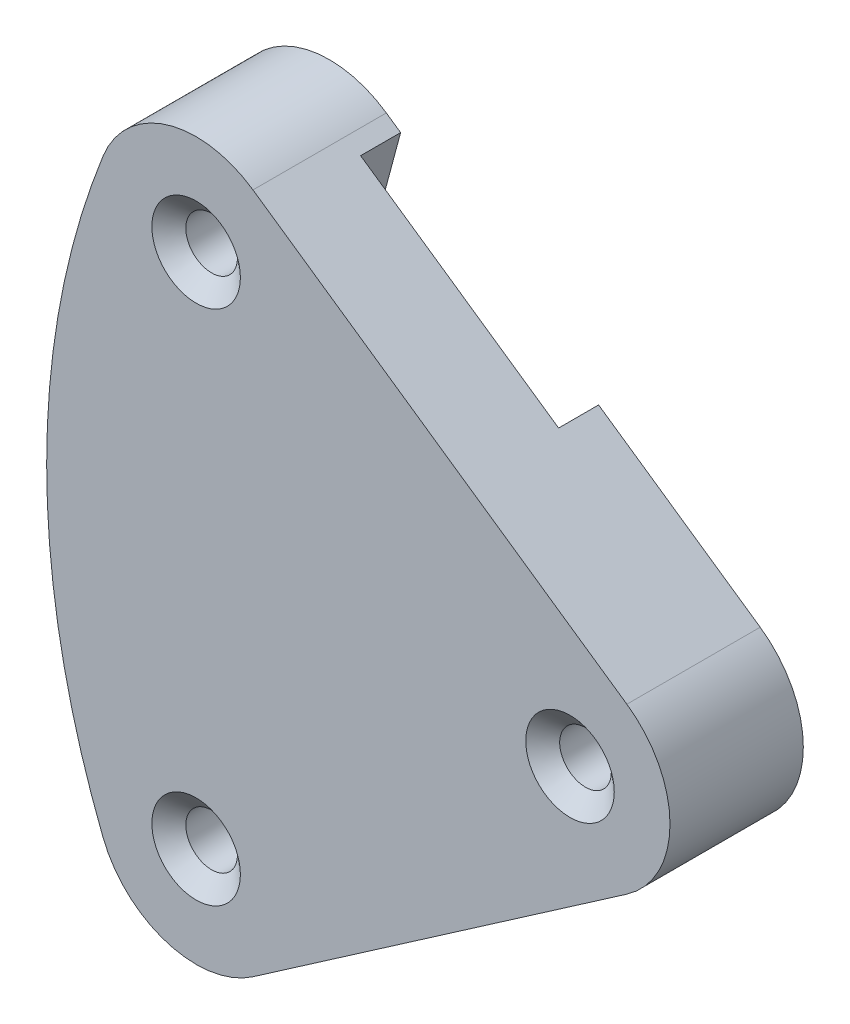
from build123d import *

# Parameters (mm, degrees)
BOSS_EXTRUDE1_DEPTH                               = 12.7
SKETCH2_R                                         = 101.6
SKETCH2_R_2                                       = 76.2
CUT_EXTRUDE1_DEPTH                                = 13.7
FILLET1_R                                         = 9.525
CSK_FOR_8_FLAT_HEAD_MACHINE_SCREW_100_D           = 4.9149
CSK_FOR_8_FLAT_HEAD_MACHINE_SCREW_100_DEPTH       = 12.7
CSK_FOR_8_FLAT_HEAD_MACHINE_SCREW_100_CSINK_D     = 8.4328
CSK_FOR_8_FLAT_HEAD_MACHINE_SCREW_100_CSINK_ANGLE = 100
CUT_EXTRUDE2_DEPTH                                = 6.35
CUT_EXTRUDE3_DEPTH                                = 3.81
SKETCH7_R                                         = 1.397
CUT_EXTRUDE4_DEPTH                                = 3.175
HOLE1_AT_2_COUNT                                  = 2
HOLE1_AT_2_PITCH                                  = 9.3599
HOLE1_AT_3_COUNT                                  = 2
HOLE1_AT_3_PITCH                                  = 38.818175673
HOLE1_AT_4_COUNT                                  = 2
HOLE1_AT_4_PITCH                                  = 40.17317123
F_2_CLEARANCE_HOLE1_D                             = 2.7051
F_2_CLEARANCE_HOLE1_DEPTH                         = 4.7625


with BuildPart() as part:
    # Sketch1 → Boss-Extrude1 (new body)
    with BuildSketch(Plane.XY):
        Polygon((33.299680929, 0), (-33.299680929, 46.0375), (-33.299680929, -46.0375), align=None)
    extrude(amount=BOSS_EXTRUDE1_DEPTH)

    # Sketch2 → Cut-Extrude1 (cut, through all)
    with BuildSketch(Plane.XY.offset(12.7)):
        with Locations((42.900319071, 0)):
            Circle(SKETCH2_R)
        with Locations((42.900319071, 0)):
            Circle(SKETCH2_R_2, mode=Mode.SUBTRACT)
    extrude(amount=-CUT_EXTRUDE1_DEPTH, mode=Mode.SUBTRACT)

    # Fillet1
    fillet1_edges = [part.edges().sort_by_distance(p)[0] for p in [
        (-22.72460624, -38.727369881, 6.35),
        (-22.72460624, 38.727369881, 6.35),
        (33.299680929, 0, 6.35),
    ]]
    fillet(fillet1_edges, radius=FILLET1_R)

    # CSK for #8 Flat Head Machine Screw (100)1
    with Locations(Plane.XY.offset(12.7)):
        with Locations((-19.063658953, -24.617494846), (-19.063658953, 24.617494846), (16.54881886, 0)):
            CounterSinkHole(CSK_FOR_8_FLAT_HEAD_MACHINE_SCREW_100_D / 2, CSK_FOR_8_FLAT_HEAD_MACHINE_SCREW_100_CSINK_D / 2, depth=CSK_FOR_8_FLAT_HEAD_MACHINE_SCREW_100_DEPTH, counter_sink_angle=CSK_FOR_8_FLAT_HEAD_MACHINE_SCREW_100_CSINK_ANGLE)

    # Sketch5 → Cut-Extrude2 (cut)
    with BuildSketch(Plane(origin=(0, 0, 0), x_dir=(-1, 0, 0), z_dir=(0, 0, -1))):
        with BuildLine():
            Line((30.823542048, 19.267389595), (-18.192319797, 6.133628997))
            ThreePointArc((-18.192319797, 6.133628997), (-22.89881886, 0), (-18.192319797, -6.133628997))
            Line((-18.192319797, -6.133628997), (30.823542048, -19.267389595))
            ThreePointArc((30.823542048, -19.267389595), (33.299680929, 0), (30.823542048, 19.267389595))
        make_face()
    extrude(amount=-CUT_EXTRUDE2_DEPTH, mode=Mode.SUBTRACT)

    # Sketch6 → Cut-Extrude3 (cut)
    with BuildSketch(Plane(origin=(0, 0, 0), x_dir=(-1, 0, 0), z_dir=(0, 0, -1))):
        Polygon((16.588726313, -15.453182214), (-4.265612277, -9.86527903), (-8.867414899, -27.039440222), (11.986923691, -32.627343405), align=None)
        Polygon((11.986923691, 32.627343405), (-8.867414899, 27.039440222), (-4.265612277, 9.86527903), (16.588726313, 15.453182214), align=None)
    extrude(amount=-CUT_EXTRUDE3_DEPTH, mode=Mode.SUBTRACT)

    # Sketch7 → Cut-Extrude4 (cut)
    with BuildSketch(Plane(origin=(0, 0, 6.35), x_dir=(-1, 0, 0), z_dir=(0, 0, -1))):
        with Locations((21.479680921, -10.189705806)):
            Circle(SKETCH7_R)
        with Locations((21.479680921, 10.189705806)):
            Circle(SKETCH7_R)
    extrude(amount=-CUT_EXTRUDE4_DEPTH, mode=Mode.SUBTRACT)

    # Sketch9 → Hole1 (revolve, cut)
    with BuildSketch(Plane(origin=(-8.904685942, -20.086585615, 3.81), x_dir=(0, 1, 0), z_dir=(1, 0, 0))):
        Polygon((0, 0), (0, 2.921), (1.4986, 2.921), (1.6383, 0), align=None)
    hole1 = revolve(axis=Axis((-8.904685942, -20.086585615, 113.81), (0, 0, -1)), mode=Mode.SUBTRACT)

    # Hole1 at 2: Hole1 ×2
    with Locations(*[Vector(0.965925826, 0.258819045, 0) * (i * HOLE1_AT_2_PITCH) for i in range(1, HOLE1_AT_2_COUNT)]):
        add(hole1, mode=Mode.SUBTRACT)

    # Hole1 at 3: Hole1 ×2
    with Locations(*[Vector(0.232905565, 0.972499356, 0) * (i * HOLE1_AT_3_PITCH) for i in range(1, HOLE1_AT_3_COUNT)]):
        add(hole1, mode=Mode.SUBTRACT)

    # Hole1 at 4: Hole1 ×2
    with Locations(*[(0, i * HOLE1_AT_4_PITCH, 0) for i in range(1, HOLE1_AT_4_COUNT)]):
        add(hole1, mode=Mode.SUBTRACT)

    # #2 Clearance Hole1
    with Locations(Plane(origin=(0, 0, 3.81), x_dir=(-1, 0, 0), z_dir=(0, 0, -1))):
        with Locations((8.904685942, -20.086585615), (-0.136283199, -17.664065235), (-0.136283199, 17.664065235), (8.904685942, 20.086585615)):
            Hole(F_2_CLEARANCE_HOLE1_D / 2, depth=F_2_CLEARANCE_HOLE1_DEPTH)


solid = part.part
